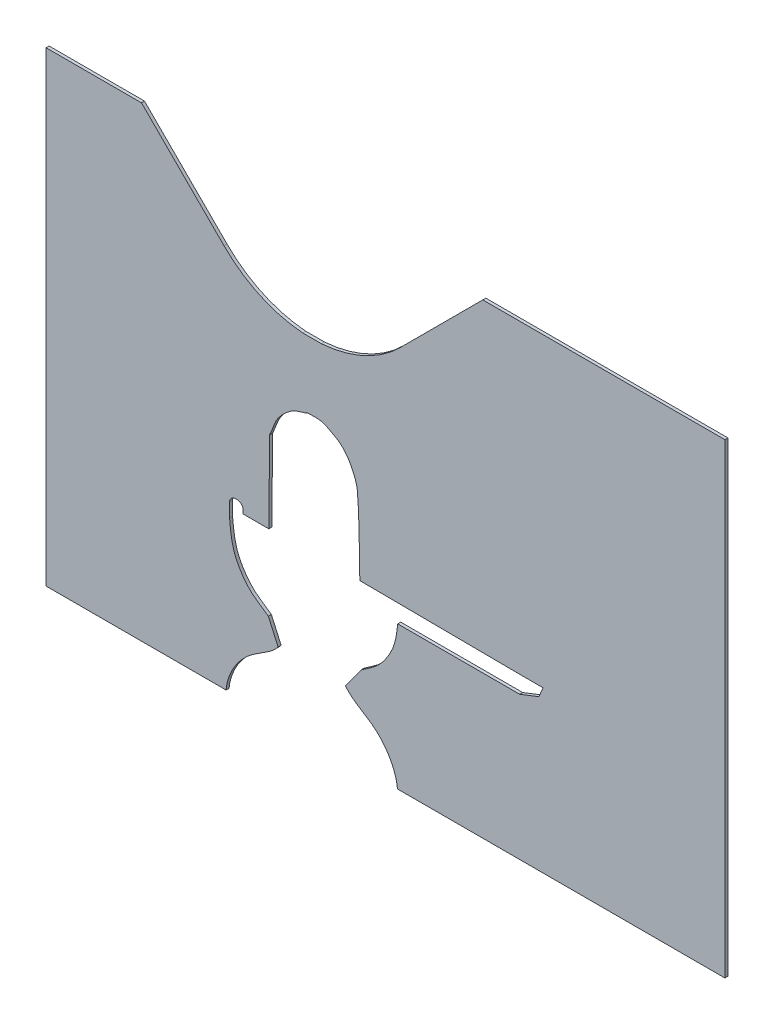
from build123d import *

# Parameters (mm, degrees)
BOSS_EXTRUDE1_DEPTH = 5
BOSS_EXTRUDE2_DEPTH = 5
CUT_EXTRUDE1_DEPTH  = 10


with BuildPart() as part:
    # Sketch1 → Boss-Extrude1 (new body)
    with BuildSketch(Plane.XY):
        with BuildLine():
            Line((370.497648791, 301.856182559), (372, 438))
            add(Edge.make_bspline(
                [(372, 438), (377.070612499, 448.141224997), (379.461430827, 459.737027004), (386, 469), (392.118159092, 477.667392046), (400.143712739, 485.158619041), (409, 491), (416.132300897, 495.704283571), (425.067091676, 496.82683667), (433, 500), (433.43768811, 500.175075244), (433.528840556, 501.015198692), (434, 501), (438.494427227, 500.855018477), (456.988046274, 503.340417023), (466, 498), (474.360530914, 493.04561131), (483.793567573, 489.520105529), (491, 483), (498.069480611, 476.603803257), (503.672468408, 468.494784236), (508, 460), (512.78479786, 450.607619016), (517.063759809, 440.499264994), (518, 430), (521.761891843, 387.813070049), (520.666666667, 345.333333333), (522, 303)],
                knots=[0, 0, 0, 0, 1, 1, 1, 2, 2, 2, 3, 3, 3, 4, 4, 4, 5, 5, 5, 6, 6, 6, 7, 7, 7, 8, 8, 8, 9, 9, 9, 9], degree=3))
            Line((522, 303), (789, 301))
            Line((789, 301), (827.03280719, 301))
            Line((827.03280719, 301), (819.918923577, 284.71793746))
            Line((819.918923577, 284.71793746), (788.046411506, 272.228043202))
            Line((788.046411506, 272.228043202), (585.155364104, 272.228043202))
            add(Edge.make_bspline(
                [(524.090153556, 175.31625705), (534.132772767, 182.776976105), (545.301104031, 188.967808356), (553.987887853, 197.958010428), (562.390275972, 206.653883218), (569.231762232, 216.980387762), (574.568753191, 227.830957202), (581.280416418, 241.476355602), (583.659025907, 256.921583072), (585.155364104, 272.228043202)],
                knots=[0.030911268, 0.030911268, 0.030911268, 0.030911268, 1, 1, 1, 2, 2, 2, 2.820581713, 2.820581713, 2.820581713, 2.820581713], degree=3))
            Line((524.090153556, 175.31625705), (497.996656044, 139.304186189))
            add(Edge.make_bspline(
                [(497.996656044, 139.304186189), (511.751798598, 122.15158093), (533.207187644, 114.760213321), (549.168786654, 100.404628372), (557.800622493, 92.641305125), (565.388182046, 83.506408445), (571.312683203, 73.52251823), (576.967291515, 63.993447834), (581.146310668, 53.41944041), (583.478086888, 42.587053902), (585.653758103, 32.479861233), (584.25512728, 21.924242773), (584.643647475, 11.592837208)],
                knots=[-0.601084915, -0.601084915, -0.601084915, -0.601084915, 1, 1, 1, 2, 2, 2, 3, 3, 3, 4, 4, 4, 4], degree=3))
            Line((584.643647475, 11.592837208), (537.046411506, 5.228043202))
            Line((537.046411506, 5.228043202), (347.046411506, 5.228043202))
            Line((347.046411506, 5.228043202), (299.449175536, 11.592837208))
            add(Edge.make_bspline(
                [(386.096166967, 139.304186189), (372.341024413, 122.15158093), (350.885635367, 114.760213321), (334.924036357, 100.404628372), (326.292200518, 92.641305125), (318.704640966, 83.506408445), (312.780139808, 73.52251823), (307.125531496, 63.993447834), (302.946512343, 53.41944041), (300.614736124, 42.587053902), (298.439064908, 32.479861233), (299.837695732, 21.924242773), (299.449175536, 11.592837208)],
                knots=[-0.601084915, -0.601084915, -0.601084915, -0.601084915, 1, 1, 1, 2, 2, 2, 3, 3, 3, 4, 4, 4, 4], degree=3))
            Line((386.096166967, 139.304186189), (369.769696723, 175.6280686))
            add(Edge.make_bspline(
                [(369.769696723, 175.6280686), (359.275993543, 183.491550102), (347.446772756, 189.833430008), (338.288587183, 199.218513107), (329.704053525, 208.015731849), (322.698000121, 218.47829637), (317.218632515, 229.481105391), (308.82128178, 246.343351742), (306.951710973, 265.954847126), (305.27920015, 284.71793746)],
                knots=[0, 0, 0, 0, 1, 1, 1, 2, 2, 2, 3, 3, 3, 3], degree=3))
            Line((305.27920015, 284.71793746), (305.27920015, 294.71793746))
            Line((305.27920015, 294.71793746), (305.27920015, 307.622403638))
            ThreePointArc((305.27920015, 307.622403638), (308.208132338, 314.69347145), (315.27920015, 317.622403638))
            Line((315.27920015, 317.622403638), (317.681970552, 317.622403638))
            ThreePointArc((317.681970552, 317.622403638), (324.753038364, 314.69347145), (327.681970552, 307.622403638))
            Line((327.681970552, 307.622403638), (327.681970552, 301.856182559))
            Line((327.681970552, 301.856182559), (370.497648791, 301.856182559))
        make_face()
        with BuildLine():
            ThreePointArc((406.611213578, 432.933993488), (444.240513417, 427.999983531), (481.869813256, 432.933993488))
            ThreePointArc((481.869813256, 432.933993488), (487.373843498, 425.711519852), (481.869813256, 418.489046215))
            ThreePointArc((481.869813256, 418.489046215), (444.240513417, 413.999983531), (406.611213578, 418.489046215))
            ThreePointArc((406.611213578, 418.489046215), (401.107183337, 425.711519852), (406.611213578, 432.933993488))
        make_face(mode=Mode.SUBTRACT)
        with BuildLine():
            ThreePointArc((406.611213578, 398), (444.240513417, 393.065990043), (481.869813256, 398))
            ThreePointArc((481.869813256, 398), (487.373843498, 390.777526364), (481.869813256, 383.555052727))
            ThreePointArc((481.869813256, 383.555052727), (444.240513417, 379.065990043), (406.611213578, 383.555052727))
            ThreePointArc((406.611213578, 383.555052727), (401.107183337, 390.777526364), (406.611213578, 398))
        make_face(mode=Mode.SUBTRACT)
        with BuildLine():
            ThreePointArc((406.611213578, 363.066006512), (444.240513417, 358.131996555), (481.869813256, 363.066006512))
            ThreePointArc((481.869813256, 363.066006512), (487.373843498, 355.843532875), (481.869813256, 348.621059239))
            ThreePointArc((481.869813256, 348.621059239), (444.240513417, 344.131996555), (406.611213578, 348.621059239))
            ThreePointArc((406.611213578, 348.621059239), (401.107183337, 355.843532875), (406.611213578, 363.066006512))
        make_face(mode=Mode.SUBTRACT)
    extrude(amount=-BOSS_EXTRUDE1_DEPTH)

    # SurfaceCut1: cut with a surface, the side behind it stays


with BuildPart() as body_2:
    # Sketch4 → Boss-Extrude2 (new body)
    with BuildSketch(Plane.XY):
        with BuildLine():
            Line((0, 809.905385878), (158.689577265, 809.905385878))
            Line((158.689577265, 809.905385878), (295.931975359, 672.662987784))
            ThreePointArc((295.931975359, 672.662987784), (356.194111544, 630.756728958), (427.274671247, 612.447889054))
            Line((427.274671247, 612.447889054), (458.100697152, 612.447889054))
            ThreePointArc((458.100697152, 612.447889054), (529.181256855, 630.756728958), (589.44339304, 672.662987784))
            Line((589.44339304, 672.662987784), (726.685791134, 809.905385878))
            Line((726.685791134, 809.905385878), (1129.472339378, 809.905385878))
            Line((1129.472339378, 809.905385878), (1129.472339378, 34.048851959))
            Line((1129.472339378, 34.048851959), (0, 34.048851959))
            Line((0, 34.048851959), (0, 809.905385878))
        make_face()
    extrude(amount=-BOSS_EXTRUDE2_DEPTH)


with BuildPart() as part_1:
    add(part.part)
    # Surface-Offset1: a surface, a copy of 1 face of the part
    surface_offset1_1 = body_2.part.faces().sort_by_distance((564.736169689, 34.048851959, -2.5))[0]
    split(bisect_by=surface_offset1_1, keep=Keep.BOTTOM)


with BuildPart() as cut_extrude1_tool:
    # Sketch5 → Cut-Extrude1 (new body)
    with BuildSketch(Plane(origin=(0, 0, -5), x_dir=(-1, 0, 0), z_dir=(0, 0, -1))):
        with BuildLine():
            Line((-305.27920015, 294.71793746), (-305.27920015, 307.622403638))
            ThreePointArc((-305.27920015, 307.622403638), (-308.208132338, 314.69347145), (-315.27920015, 317.622403638))
            Line((-315.27920015, 317.622403638), (-317.681970552, 317.622403638))
            ThreePointArc((-317.681970552, 317.622403638), (-324.753038364, 314.69347145), (-327.681970552, 307.622403638))
            Line((-327.681970552, 307.622403638), (-327.681970552, 301.856182559))
            Line((-327.681970552, 301.856182559), (-370.497648791, 301.856182559))
            Line((-370.497648791, 301.856182559), (-372, 438))
            add(Edge.make_bspline(
                [(-372, 438), (-377.070612499, 448.141224997), (-379.461430827, 459.737027004), (-386, 469), (-392.118159092, 477.667392046), (-400.143712739, 485.158619041), (-409, 491), (-416.132300897, 495.704283571), (-425.067091676, 496.82683667), (-433, 500), (-433.43768811, 500.175075244), (-433.528840556, 501.015198692), (-434, 501), (-438.494427227, 500.855018477), (-456.988046274, 503.340417023), (-466, 498), (-474.360530914, 493.04561131), (-483.793567573, 489.520105529), (-491, 483), (-498.069480611, 476.603803257), (-503.672468408, 468.494784236), (-508, 460), (-512.78479786, 450.607619016), (-517.063759809, 440.499264994), (-518, 430), (-521.761891843, 387.813070049), (-520.666666667, 345.333333333), (-522, 303)],
                knots=[0, 0, 0, 0, 1, 1, 1, 2, 2, 2, 3, 3, 3, 4, 4, 4, 5, 5, 5, 6, 6, 6, 7, 7, 7, 8, 8, 8, 9, 9, 9, 9], degree=3))
            Line((-522, 303), (-789, 301))
            Line((-789, 301), (-827.03280719, 301))
            Line((-827.03280719, 301), (-819.918923577, 284.71793746))
            Line((-819.918923577, 284.71793746), (-788.046411506, 272.228043202))
            Line((-788.046411506, 272.228043202), (-585.155364104, 272.228043202))
            add(Edge.make_bspline(
                [(-585.155364104, 272.228043202), (-583.659025907, 256.921583072), (-581.280416418, 241.476355602), (-574.568753191, 227.830957202), (-569.231762232, 216.980387762), (-562.390275972, 206.653883218), (-553.987887853, 197.958010428), (-545.301104031, 188.967808356), (-534.132772767, 182.776976105), (-524.090153556, 175.31625705)],
                knots=[0.030911268, 0.030911268, 0.030911268, 0.030911268, 0.851492981, 0.851492981, 0.851492981, 1.851492981, 1.851492981, 1.851492981, 2.820581713, 2.820581713, 2.820581713, 2.820581713], degree=3))
            Line((-524.090153556, 175.31625705), (-497.996656044, 139.304186189))
            add(Edge.make_bspline(
                [(-497.996656044, 139.304186189), (-511.751798598, 122.15158093), (-533.207187644, 114.760213321), (-549.168786654, 100.404628372), (-557.800622493, 92.641305125), (-565.388182046, 83.506408445), (-571.312683203, 73.52251823), (-576.967291515, 63.993447834), (-581.146310668, 53.41944041), (-583.478086888, 42.587053902), (-585.653758103, 32.479861233), (-584.25512728, 21.924242773), (-584.643647475, 11.592837208)],
                knots=[-0.601084915, -0.601084915, -0.601084915, -0.601084915, 1, 1, 1, 2, 2, 2, 3, 3, 3, 4, 4, 4, 4], degree=3))
            Line((-584.643647475, 11.592837208), (-537.046411506, 5.228043202))
            Line((-537.046411506, 5.228043202), (-347.046411506, 5.228043202))
            Line((-347.046411506, 5.228043202), (-299.449175536, 11.592837208))
            add(Edge.make_bspline(
                [(-299.449175536, 11.592837208), (-299.837695732, 21.924242773), (-298.439064908, 32.479861233), (-300.614736124, 42.587053902), (-302.946512343, 53.41944041), (-307.125531496, 63.993447834), (-312.780139808, 73.52251823), (-318.704640966, 83.506408445), (-326.292200518, 92.641305125), (-334.924036357, 100.404628372), (-350.885635367, 114.760213321), (-372.341024413, 122.15158093), (-386.096166967, 139.304186189)],
                knots=[-0.601084915, -0.601084915, -0.601084915, -0.601084915, 0.398915085, 0.398915085, 0.398915085, 1.398915085, 1.398915085, 1.398915085, 2.398915085, 2.398915085, 2.398915085, 4, 4, 4, 4], degree=3))
            Line((-386.096166967, 139.304186189), (-369.769696723, 175.6280686))
            add(Edge.make_bspline(
                [(-369.769696723, 175.6280686), (-359.275993543, 183.491550102), (-347.446772756, 189.833430008), (-338.288587183, 199.218513107), (-329.704053525, 208.015731849), (-322.698000121, 218.47829637), (-317.218632515, 229.481105391), (-308.82128178, 246.343351742), (-306.951710973, 265.954847126), (-305.27920015, 284.71793746)],
                knots=[0, 0, 0, 0, 1, 1, 1, 2, 2, 2, 3, 3, 3, 3], degree=3))
            Line((-305.27920015, 284.71793746), (-305.27920015, 294.71793746))
        make_face()
    extrude(amount=-CUT_EXTRUDE1_DEPTH)


with BuildPart() as part_2:
    add(part_1.part)

    # Cut-Extrude1: cut by cut_extrude1_tool
    add(cut_extrude1_tool.part, mode=Mode.SUBTRACT)


with BuildPart() as body_2_1:
    add(body_2.part)

    # Cut-Extrude1: cut by cut_extrude1_tool
    add(cut_extrude1_tool.part, mode=Mode.SUBTRACT)


solid = body_2_1.part
